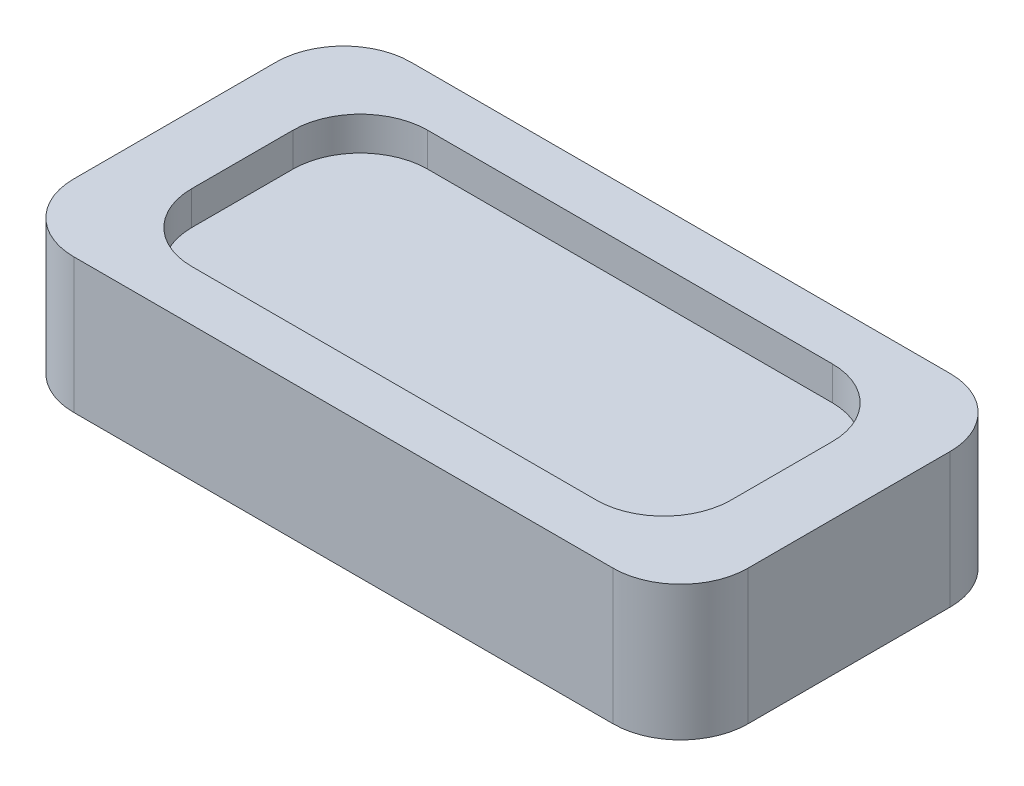
from build123d import *

# Parameters (mm, degrees)
SKETCH1_W           = 100
SKETCH1_H           = 50
BOSS_EXTRUDE1_DEPTH = 20
SKETCH2_W           = 80
SKETCH2_H           = 35
CUT_EXTRUDE1_DEPTH  = 5
FILLET1_R           = 10
FILLET2_R           = 10


with BuildPart() as part:
    # Sketch1 → Boss-Extrude1 (new body)
    with BuildSketch(Plane(origin=(0, 0, 0), x_dir=(1, 0, 0), z_dir=(0, 1, 0))):
        Rectangle(SKETCH1_W, SKETCH1_H)
    extrude(amount=BOSS_EXTRUDE1_DEPTH)

    # Sketch2 → Cut-Extrude1 (cut)
    with BuildSketch(Plane(origin=(0, 20, 0), x_dir=(1, 0, 0), z_dir=(0, 1, 0))):
        Rectangle(SKETCH2_W, SKETCH2_H)
    extrude(amount=-CUT_EXTRUDE1_DEPTH, mode=Mode.SUBTRACT)

    # Fillet1
    fillet1_edges = [part.edges().sort_by_distance(p)[0] for p in [
        (-50, 10, -25),
        (50, 10, -25),
        (50, 10, 25),
        (-50, 10, 25),
    ]]
    fillet(fillet1_edges, radius=FILLET1_R)

    # Fillet2
    fillet2_edges = [part.edges().sort_by_distance(p)[0] for p in [
        (-40, 17.5, 17.5),
        (-40, 17.5, -17.5),
        (40, 17.5, -17.5),
        (40, 17.5, 17.5),
    ]]
    fillet(fillet2_edges, radius=FILLET2_R)


solid = part.part
